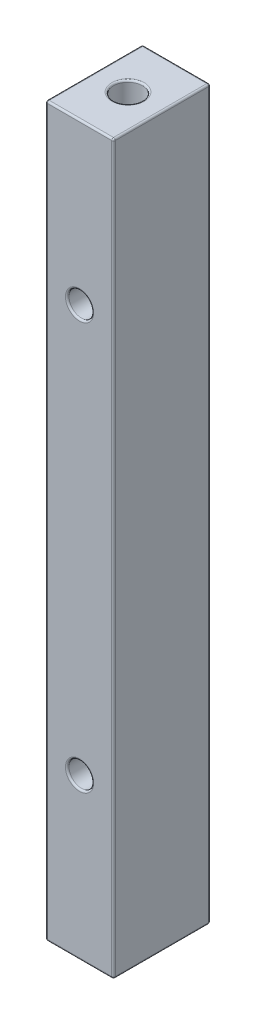
from build123d import *

# Parameters (mm, degrees)
SKETCH1_W                = 9.525
SKETCH1_H                = 13.59916
SKETCH1_R                = 2.0193
BOSS_EXTRUDE1_DEPTH      = 51.054
SKETCH2_R                = 2.0193
BOSS_EXTRUDE2_DEPTH      = 38.354
BOSS_EXTRUDE2_DEPTH_BACK = 38.354
SKETCH4_R                = 1.7272
CUT_EXTRUDE1_DEPTH       = 13.59916
FILLET2_R                = 0.254


with BuildPart() as part:
    # Sketch1 → Boss-Extrude1 (new body, symmetric)
    with BuildSketch(Plane(origin=(0, 0, 0), x_dir=(1, 0, 0), z_dir=(0, 1, 0))):
        Rectangle(SKETCH1_W, SKETCH1_H)
        Circle(SKETCH1_R, mode=Mode.SUBTRACT)
    extrude(amount=BOSS_EXTRUDE1_DEPTH, both=True)

    # Sketch2 → Boss-Extrude2 (add, two sides)
    with BuildSketch(Plane(origin=(0, 0, 0), x_dir=(1, 0, 0), z_dir=(0, 1, 0))) as boss_extrude2_sk:
        Circle(SKETCH2_R)
    extrude(amount=BOSS_EXTRUDE2_DEPTH)
    extrude(boss_extrude2_sk.sketch, amount=-BOSS_EXTRUDE2_DEPTH_BACK)

    # Sketch4 → Cut-Extrude1 (cut)
    with BuildSketch(Plane(origin=(0, 0, -6.79958), x_dir=(-1, 0, 0), z_dir=(0, 0, -1))):
        with Locations((0, 28.575)):
            Circle(SKETCH4_R)
        with Locations((0, -28.575)):
            Circle(SKETCH4_R)
    extrude(amount=-CUT_EXTRUDE1_DEPTH, mode=Mode.SUBTRACT)

    # Fillet2
    fillet2_edges = [part.edges().sort_by_distance(p)[0] for p in [
        (-4.7625, 51.054, 0),
        (-2.0193, -51.054, 0),
        (-2.0193, 51.054, 0),
        (0, 51.054, 6.79958),
        (1.7272, 28.575, -6.79958),
        (1.7272, 28.575, 6.79958),
        (1.7272, -28.575, -6.79958),
        (1.7272, -28.575, 6.79958),
        (4.7625, 51.054, 0),
        (0, -51.054, 6.79958),
        (-4.7625, -51.054, 0),
        (0, -51.054, -6.79958),
        (4.7625, -51.054, 0),
        (0, 51.054, -6.79958),
        (4.7625, 0, 6.79958),
        (-4.7625, 0, 6.79958),
        (-4.7625, 0, -6.79958),
        (4.7625, 0, -6.79958),
    ]]
    fillet(fillet2_edges, radius=FILLET2_R)


solid = part.part
